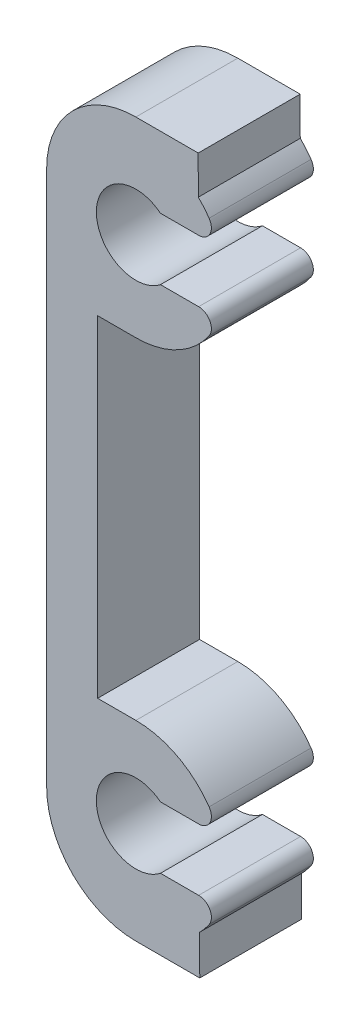
from build123d import *

# Parameters (mm, degrees)
BOSS_EXTRUDE1_DEPTH = 4
CUT_EXTRUDE4_REACH  = 6
SKETCH2_R           = 1.55
CUT_EXTRUDE5_DEPTH  = 5
FILLET1_R           = 0.5


with BuildPart() as part:
    # Sketch1 → Boss-Extrude1 (new body)
    with BuildSketch(Plane.XY):
        with BuildLine():
            Line((-10, 14), (-7.553754025, 14))
            Line((-7.553754025, 14), (-7.550510257, 12.5))
            ThreePointArc((-7.550510257, 12.5), (-6.759629651, 8.677124344), (-10, 6.5))
            Line((-10, 6.5), (-11.5, 6.5))
            Line((-11.5, 6.5), (-11.5, -6.5))
            Line((-11.5, -6.5), (-10, -6.5))
            ThreePointArc((-10, -6.5), (-6.774250172, -8.641862287), (-7.496564289, -12.445978258))
            Line((-7.496564289, -12.445978258), (-7.493203699, -14))
            Line((-7.493203699, -14), (-10, -14))
            ThreePointArc((-10, -14), (-12.474873734, -12.974873734), (-13.5, -10.5))
            Line((-13.5, -10.5), (-13.5, 10.5))
            ThreePointArc((-13.5, 10.5), (-12.474873734, 12.974873734), (-10, 14))
        make_face()
    extrude(amount=BOSS_EXTRUDE1_DEPTH)

    # Sketch2 → Cut-Extrude4 (cut, up to next)
    with BuildSketch(Plane.XY, mode=Mode.PRIVATE) as cut_extrude4_sk1:
        with Locations((-10, -10)):
            Circle(SKETCH2_R)
    cut_extrude4_tool1 = extrude(cut_extrude4_sk1.sketch, amount=CUT_EXTRUDE4_REACH, mode=Mode.PRIVATE) & part.part
    add(cut_extrude4_tool1.solids().sort_by_distance((-10, -10, 0))[0], mode=Mode.SUBTRACT)
    # Sketch2 → Cut-Extrude4 (cut, up to next)
    with BuildSketch(Plane.XY, mode=Mode.PRIVATE) as cut_extrude4_sk2:
        with Locations((-10, 10)):
            Circle(SKETCH2_R)
    cut_extrude4_tool2 = extrude(cut_extrude4_sk2.sketch, amount=CUT_EXTRUDE4_REACH, mode=Mode.PRIVATE) & part.part
    add(cut_extrude4_tool2.solids().sort_by_distance((-10, 10, 0))[0], mode=Mode.SUBTRACT)

    # Sketch3 → Cut-Extrude5 (cut, through all)
    with BuildSketch(Plane.XY.offset(4)):
        with BuildLine():
            Line((-9.034256252, 11.212369174), (-6.716684452, 11.212369174))
            ThreePointArc((-6.716684452, 11.212369174), (-6.5, 10), (-6.716684452, 8.787630826))
            Line((-6.716684452, 8.787630826), (-9.034256252, 8.787630826))
            ThreePointArc((-9.034256252, 8.787630826), (-8.45, 10), (-9.034256252, 11.212369174))
        make_face()
    cut_extrude5 = extrude(amount=-CUT_EXTRUDE5_DEPTH, mode=Mode.SUBTRACT)

    # Mirror1: Cut-Extrude5 across plane
    add(cut_extrude5.mirror(Plane(origin=(0, 0, 0), x_dir=(0, 0, 1), z_dir=(0, -1, 0))), mode=Mode.SUBTRACT)

    # Fillet1
    fillet1_edges = [part.edges().sort_by_distance(p)[0] for p in [
        (-6.716684452, 11.212369174, 2),
        (-6.716684452, 8.787630826, 2),
        (-6.716684452, -8.787630826, 2),
        (-6.716684452, -11.212369174, 2),
    ]]
    fillet(fillet1_edges, radius=FILLET1_R)


solid = part.part
